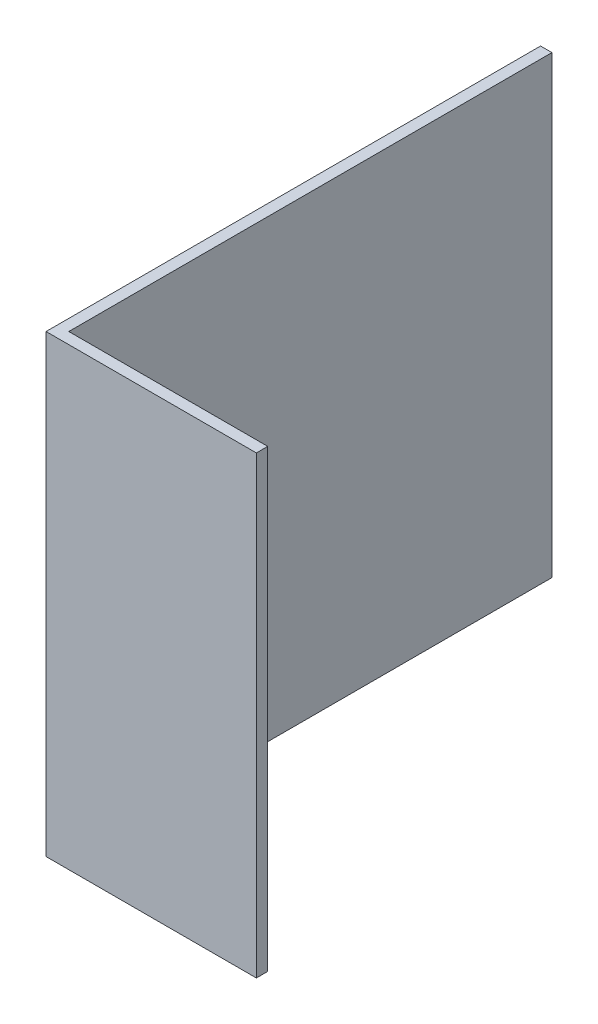
from build123d import *

# Parameters (mm, degrees)
SKETCH_1_W      = 2
SKETCH_1_H      = 87
EXTRUDE_1_DEPTH = 40
SKETCH_2_W      = 2
SKETCH_2_H      = 80
EXTRUDE_2_DEPTH = 35


with BuildPart() as part:
    # 草图1 → 凸台-拉伸1 (new body, symmetric)
    with BuildSketch(Plane(origin=(0, 0, 0), x_dir=(1, 0, 0), z_dir=(0, 1, 0))):
        with Locations((-1, 43.5)):
            Rectangle(SKETCH_1_W, SKETCH_1_H)
    extrude(amount=EXTRUDE_1_DEPTH, both=True)

    # 草图2 → 凸台-拉伸2 (add)
    with BuildSketch(Plane(origin=(0, 0, 0), x_dir=(0, 0, -1), z_dir=(1, 0, 0))):
        with Locations((1, 0)):
            Rectangle(SKETCH_2_W, SKETCH_2_H)
    extrude(amount=EXTRUDE_2_DEPTH)


solid = part.part
